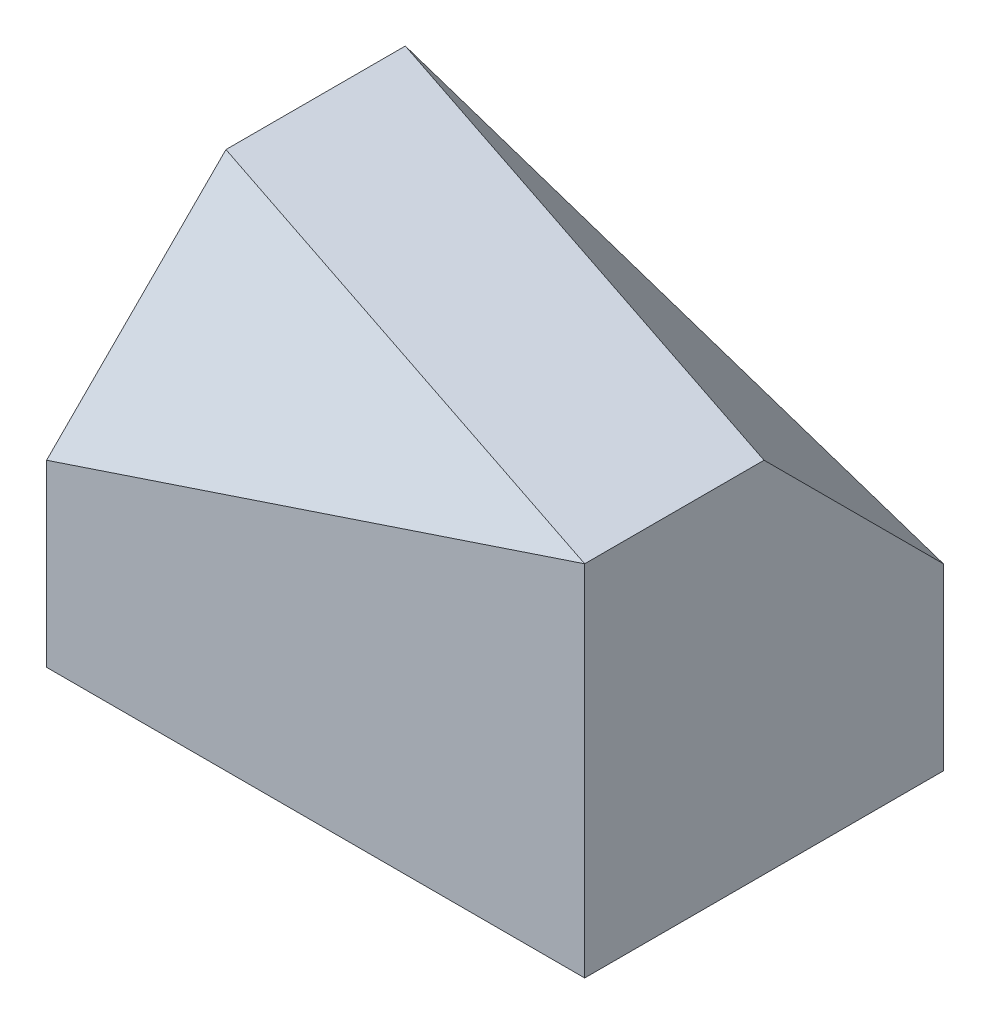
from build123d import *

# Parameters (mm, degrees)
SKETCH_1_W          = 6
SKETCH_1_H          = 4
EXTRUDE_1_DEPTH     = 4
CUT_EXTRUDE_1_DEPTH = 4
SKETCH_10_W         = 32.252295377
SKETCH_10_H         = 15.179180951
CUT_EXTRUDE_2_DEPTH = 5


with BuildPart() as part:
    # 草圖1 → 填料-伸長1 (new body)
    with BuildSketch(Plane(origin=(0, 0, 0), x_dir=(1, 0, 0), z_dir=(0, 1, 0))):
        Rectangle(SKETCH_1_W, SKETCH_1_H)
    extrude(amount=EXTRUDE_1_DEPTH)

    # 草圖6 → 除料-伸長1 (cut)
    with BuildSketch(Plane(origin=(0.789473684, 2.368421053, -2.368421053), x_dir=(0.973328527, -0.162221421, 0.162221421), z_dir=(-0.229415734, -0.688247202, 0.688247202))):
        Polygon((0, 0), (-20.538761547, 0), (-20.538761547, 12.535207186), (11.71353383, 14.625633738), (12.268136792, -0.263322726), align=None)
    extrude(amount=-CUT_EXTRUDE_1_DEPTH, mode=Mode.SUBTRACT)

    # 草圖10 → 除料-伸長2 (cut)
    with BuildSketch(Plane(origin=(-0.789473684, 2.368421053, 2.368421053), x_dir=(0.973328527, 0.162221421, 0.162221421), z_dir=(-0.229415734, 0.688247202, 0.688247202))):
        with Locations((3.943334428, 7.114500239)):
            Rectangle(SKETCH_10_W, SKETCH_10_H)
    extrude(amount=CUT_EXTRUDE_2_DEPTH, mode=Mode.SUBTRACT)


solid = part.part
